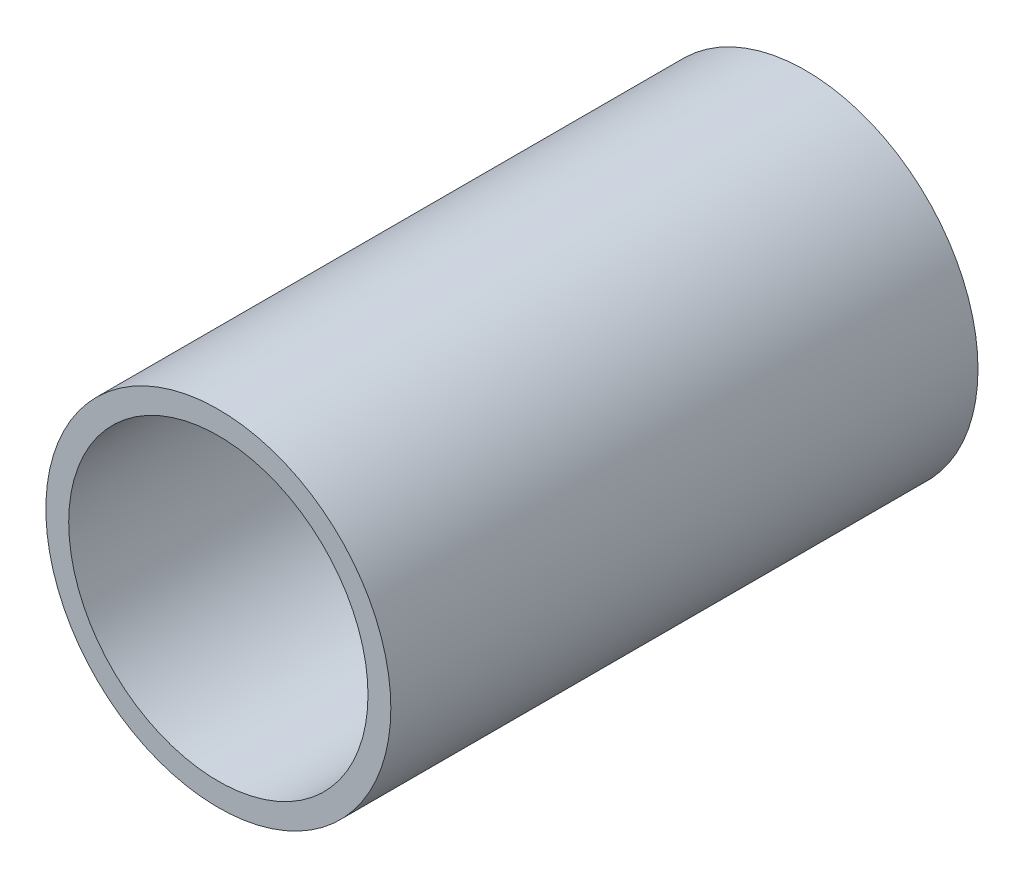
from build123d import *

# Parameters (mm, degrees)
SKETCH1_R           = 7.55
SKETCH1_R_2         = 6.55
BOSS_EXTRUDE1_DEPTH = 25.7


with BuildPart() as part:
    # Sketch1 → Boss-Extrude1 (new body)
    with BuildSketch(Plane.XY):
        Circle(SKETCH1_R)
        Circle(SKETCH1_R_2, mode=Mode.SUBTRACT)
    extrude(amount=BOSS_EXTRUDE1_DEPTH)


solid = part.part
